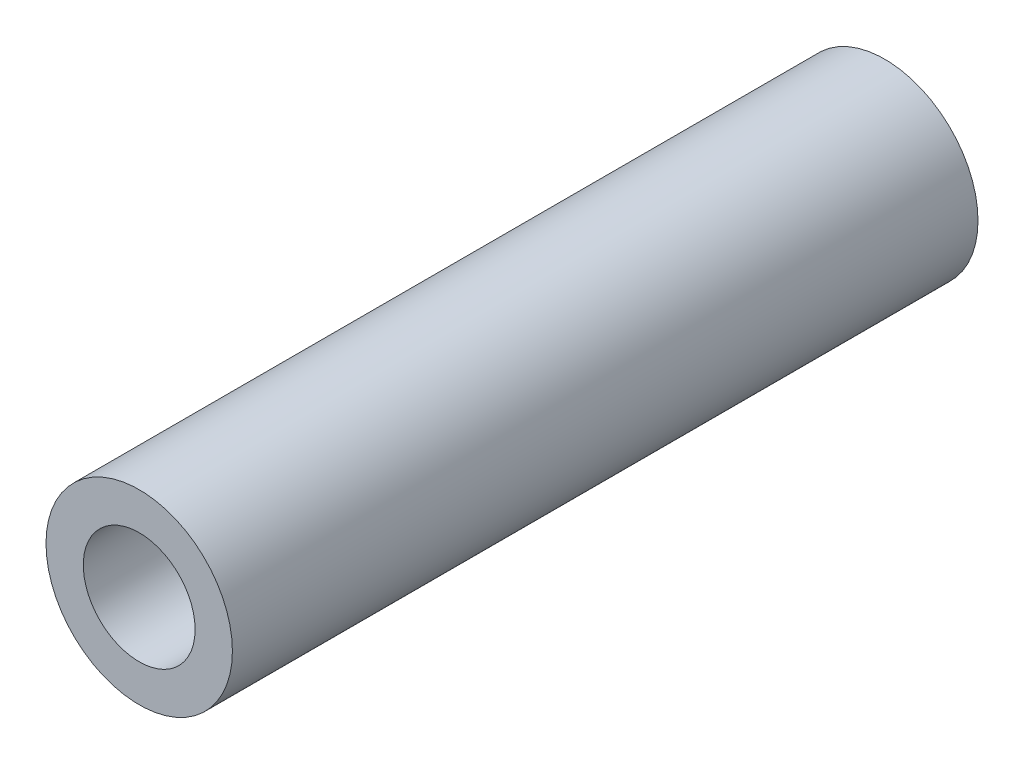
from build123d import *

# Parameters (mm, degrees)
SKETCH_1_R      = 2.5
SKETCH_1_R_2    = 1.5
EXTRUDE_1_DEPTH = 10


with BuildPart() as part:
    # 草图1 → 凸台-拉伸1 (new body, symmetric)
    with BuildSketch(Plane.XY):
        Circle(SKETCH_1_R)
        Circle(SKETCH_1_R_2, mode=Mode.SUBTRACT)
    extrude(amount=EXTRUDE_1_DEPTH, both=True)


solid = part.part
